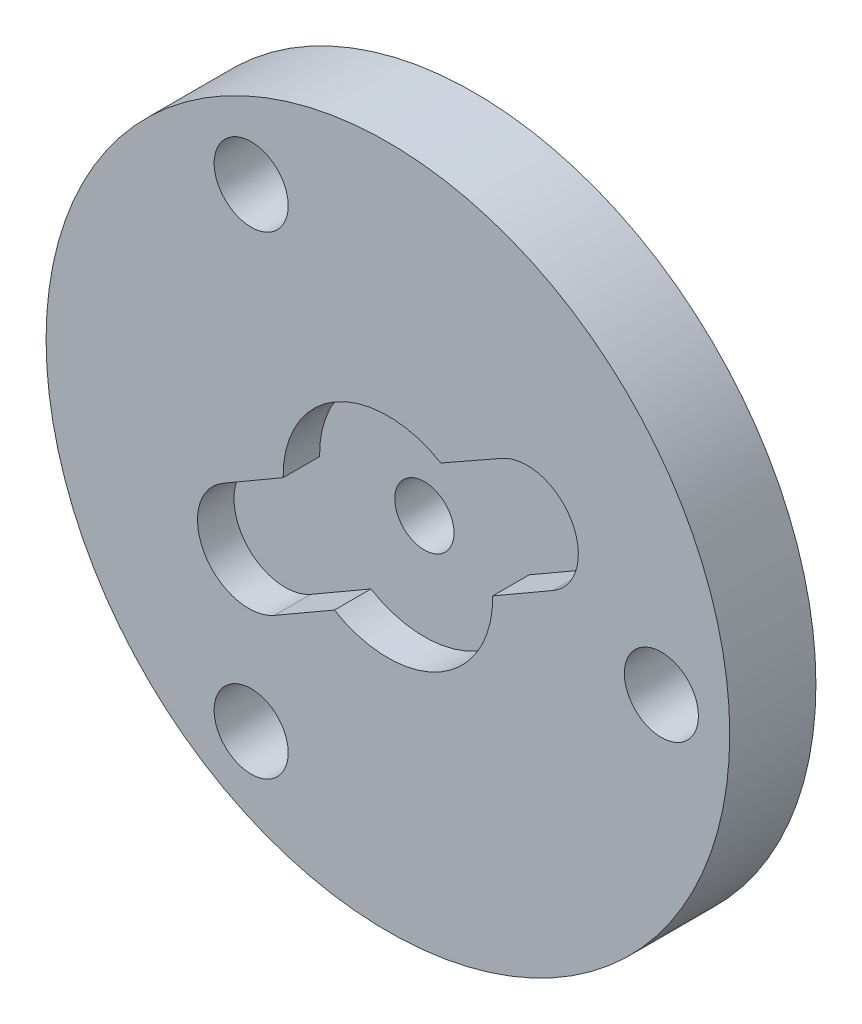
from build123d import *

# Parameters (mm, degrees)
SCHIZZO1_R                   = 15
ESTRUSIONE_ESTRUSIONE1_DEPTH = 3.781092502
SCHIZZO2_R                   = 1.625
SCHIZZO2_R_2                 = 1.3
TAGLIO_ESTRUSIONE1_DEPTH     = 4.781092502
SCHIZZO3_R                   = 1.3
TAGLIO_ESTRUSIONE2_DEPTH     = 1.6


with BuildPart() as part:
    # Schizzo1 → Estrusione-Estrusione1 (new body)
    with BuildSketch(Plane.XY):
        Circle(SCHIZZO1_R)
    extrude(amount=ESTRUSIONE_ESTRUSIONE1_DEPTH)

    # Schizzo2 → Taglio-Estrusione1 (cut, through all)
    with BuildSketch(Plane.XY.offset(3.781092502)):
        with Locations((12, 0)):
            Circle(SCHIZZO2_R)
        with Locations((-6, 10.392304845)):
            Circle(SCHIZZO2_R)
        with Locations((-6, -10.392304845)):
            Circle(SCHIZZO2_R)
        Circle(SCHIZZO2_R_2)
    extrude(amount=-TAGLIO_ESTRUSIONE1_DEPTH, mode=Mode.SUBTRACT)

    # Schizzo3 → Taglio-Estrusione2 (cut)
    with BuildSketch(Plane.XY.offset(3.781092502)):
        with BuildLine():
            Line((2.324693054, 3.969357908), (-7.234922947, -1.579015265))
            ThreePointArc((-7.234922947, -1.579015265), (-8.052751546, -4.652222254), (-4.980479907, -5.473557626))
            Line((-4.980479907, -5.473557626), (7.230479097, 1.576442841))
            ThreePointArc((7.230479097, 1.576442841), (8.058653282, 4.641964906), (4.996568233, 5.482758079))
            Line((4.996568233, 5.482758079), (2.324693054, 3.969357908))
        make_face()
        Circle(SCHIZZO3_R, mode=Mode.SUBTRACT)
        with BuildLine():
            Line((-4.599733028, -0.049558742), (-1.133047311, 1.962495511))
            Line((-1.133047311, 1.962495511), (-2.3, 3.983716857))
            ThreePointArc((-2.3, 3.983716857), (-3.996048921, 2.278506752), (-4.599733028, -0.049558742))
        make_face()
        with BuildLine():
            Line((-2.3, 3.983716857), (-1.133047311, 1.962495511))
            Line((-1.133047311, 1.962495511), (2.324693054, 3.969357908))
            ThreePointArc((2.324693054, 3.969357908), (0.014282212, 4.599977828), (-2.3, 3.983716857))
        make_face()
        with BuildLine():
            ThreePointArc((-2.349640269, -3.954641653), (2.3, -3.983716857), (4.599640269, 0.057527336))
            Line((4.599640269, 0.057527336), (-2.349640269, -3.954641653))
        make_face()
    extrude(amount=-TAGLIO_ESTRUSIONE2_DEPTH, mode=Mode.SUBTRACT)


solid = part.part
